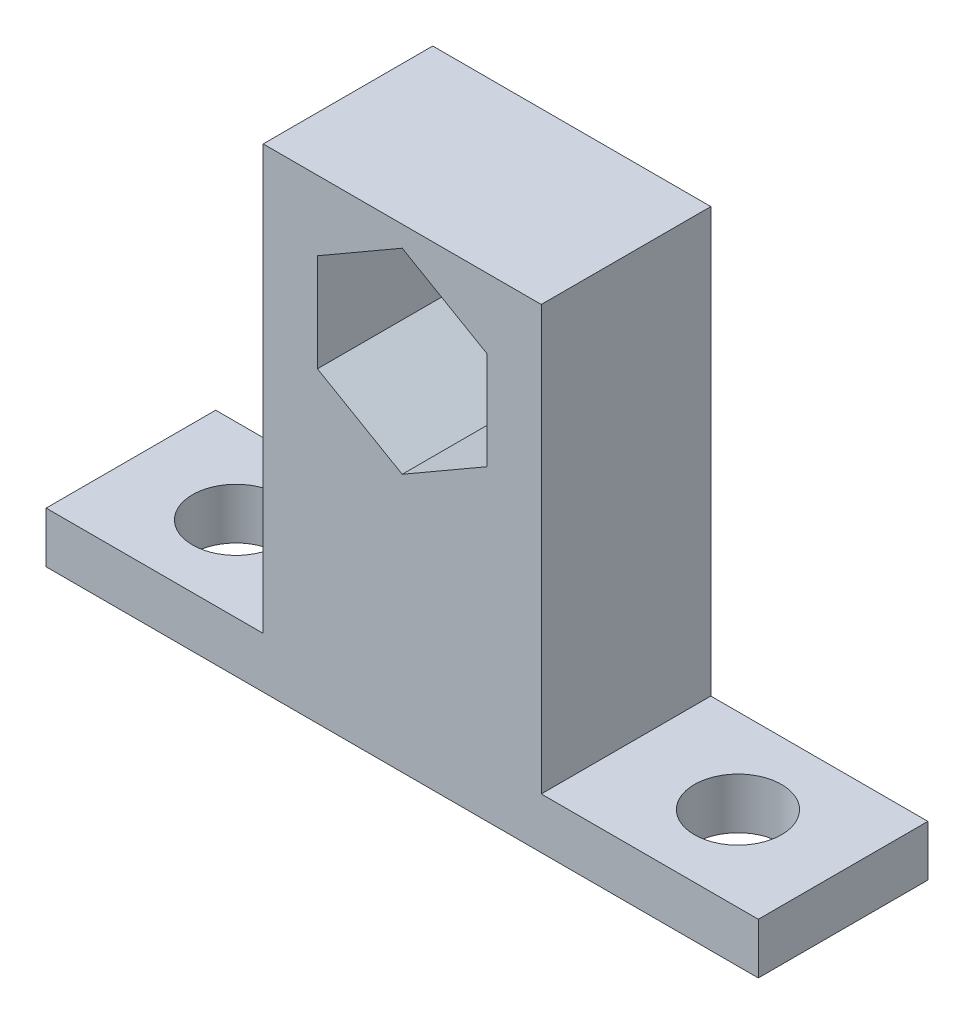
from build123d import *

# Parameters (mm, degrees)
SKETCH1_W           = 15.494
SKETCH1_H           = 12.7
SKETCH1_R           = 3.2639
SKETCH1_W_2         = 22.352
BOSS_EXTRUDE3_DEPTH = 3.81
SKETCH3_W           = 20.828
SKETCH3_H           = 12.7
BOSS_EXTRUDE4_DEPTH = 31.75
CUT_EXTRUDE3_REACH  = 14.7


with BuildPart() as part:
    # Sketch1 → Boss-Extrude3 (new body)
    with BuildSketch(Plane(origin=(0, 0, 0), x_dir=(1, 0, 0), z_dir=(0, 1, 0))):
        with Locations((-27.634045528, -3.236090754)):
            Rectangle(SKETCH1_W, SKETCH1_H)
        with Locations((-27.507045528, -3.236090754)):
            Circle(SKETCH1_R, mode=Mode.SUBTRACT)
        with Locations((-8.711045528, -3.236090754)):
            Rectangle(SKETCH1_W_2, SKETCH1_H)
        with Locations((10.211954472, -3.236090754)):
            Rectangle(SKETCH1_W, SKETCH1_H)
        with Locations((10.084954472, -3.236090754)):
            Circle(SKETCH1_R, mode=Mode.SUBTRACT)
    extrude(amount=BOSS_EXTRUDE3_DEPTH)

    # Sketch3 → Boss-Extrude4 (add)
    with BuildSketch(Plane(origin=(0, 3.81, 0), x_dir=(1, 0, 0), z_dir=(0, 1, 0))):
        with Locations((-8.711045528, -3.236090754)):
            Rectangle(SKETCH3_W, SKETCH3_H)
    extrude(amount=BOSS_EXTRUDE4_DEPTH)

    # Sketch5 → Cut-Extrude3 (cut, up to next)
    with BuildSketch(Plane(origin=(0, 0, -3.113909246), x_dir=(-1, 0, 0), z_dir=(0, 0, -1)), mode=Mode.PRIVATE) as cut_extrude3_sk1:
        Polygon((8.711045528, 34.002348419), (2.361045528, 30.336174209), (2.361045528, 23.003825791), (8.711045528, 19.337651581), (15.061045528, 23.003825791), (15.061045528, 30.336174209), align=None)
    cut_extrude3_tool1 = extrude(cut_extrude3_sk1.sketch, amount=-CUT_EXTRUDE3_REACH, mode=Mode.PRIVATE) & part.part
    add(cut_extrude3_tool1.solids().sort_by_distance((-8.711046, 26.67, -3.113909))[0], mode=Mode.SUBTRACT)


solid = part.part
